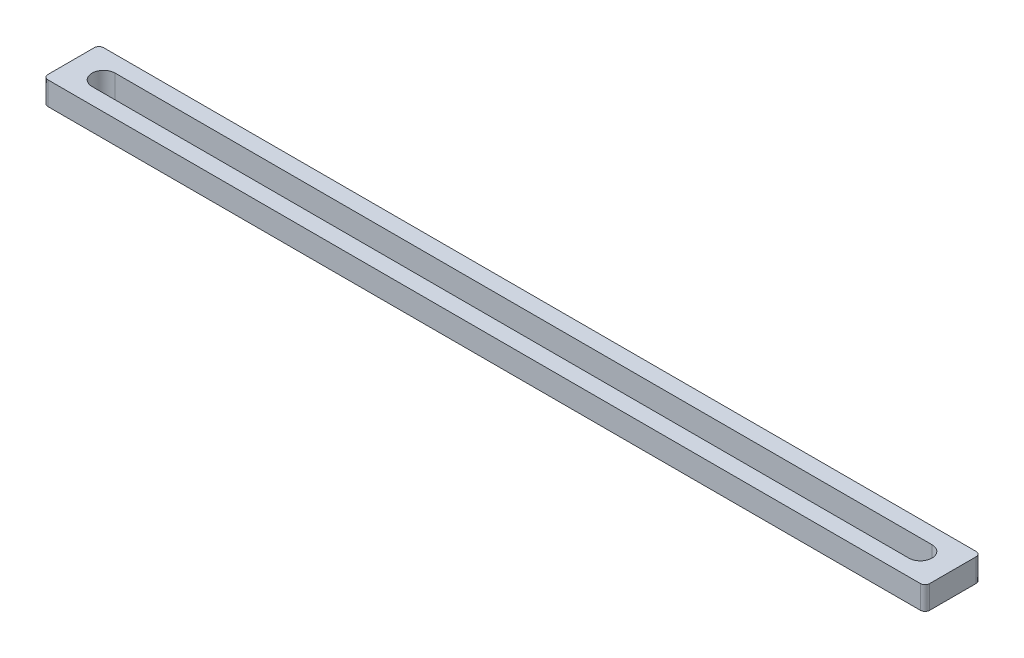
from build123d import *

# Parameters (mm, degrees)
ESQUISSE1_W        = 190
ESQUISSE1_H        = 12
BOSS_EXTRU_1_DEPTH = 2.5
CONG_2_R           = 1


with BuildPart() as part:
    # Esquisse1 → Boss.-Extru.1 (new body, symmetric)
    with BuildSketch(Plane(origin=(0, 0, 0), x_dir=(1, 0, 0), z_dir=(0, 1, 0))):
        Rectangle(ESQUISSE1_W, ESQUISSE1_H)
        with BuildLine():
            Line((-88, 2.5), (88, 2.5))
            ThreePointArc((88, 2.5), (90.5, 0), (88, -2.5))
            Line((88, -2.5), (-88, -2.5))
            ThreePointArc((-88, -2.5), (-90.5, 0), (-88, 2.5))
        make_face(mode=Mode.SUBTRACT)
    extrude(amount=BOSS_EXTRU_1_DEPTH, both=True)

    # Congé2
    cong_2_edges = [part.edges().sort_by_distance(p)[0] for p in [
        (95, 0, 6),
        (-95, 0, 6),
        (-95, 0, -6),
        (95, 0, -6),
    ]]
    fillet(cong_2_edges, radius=CONG_2_R)


solid = part.part
